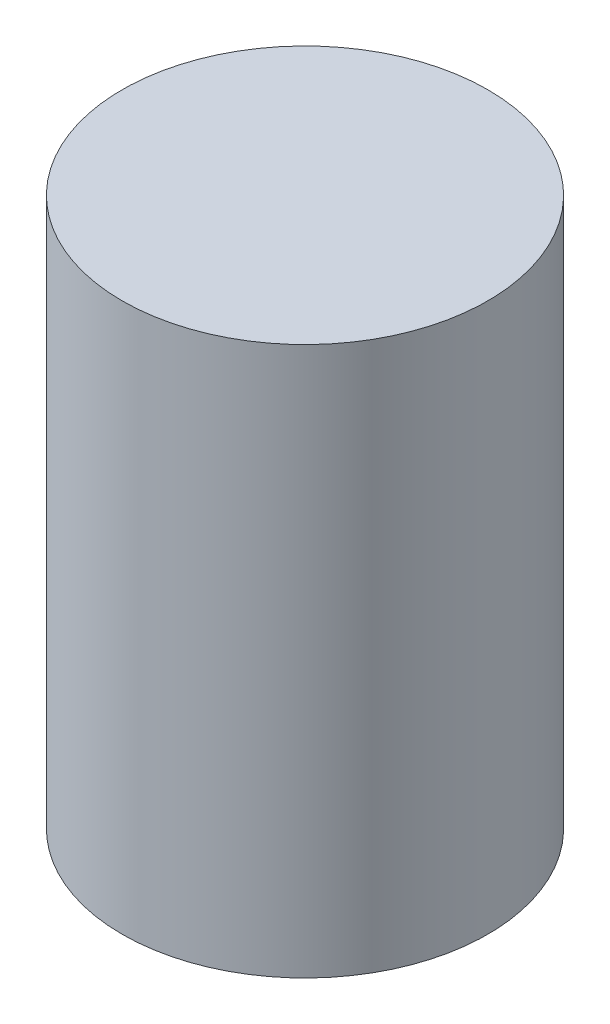
from build123d import *

# Parameters (mm, degrees)
SKETCH1_R           = 5
BOSS_EXTRUDE1_DEPTH = 15


with BuildPart() as part:
    # Sketch1 → Boss-Extrude1 (new body)
    with BuildSketch(Plane(origin=(0, 0, 0), x_dir=(1, 0, 0), z_dir=(0, 1, 0))):
        Circle(SKETCH1_R)
    extrude(amount=BOSS_EXTRUDE1_DEPTH)


solid = part.part
